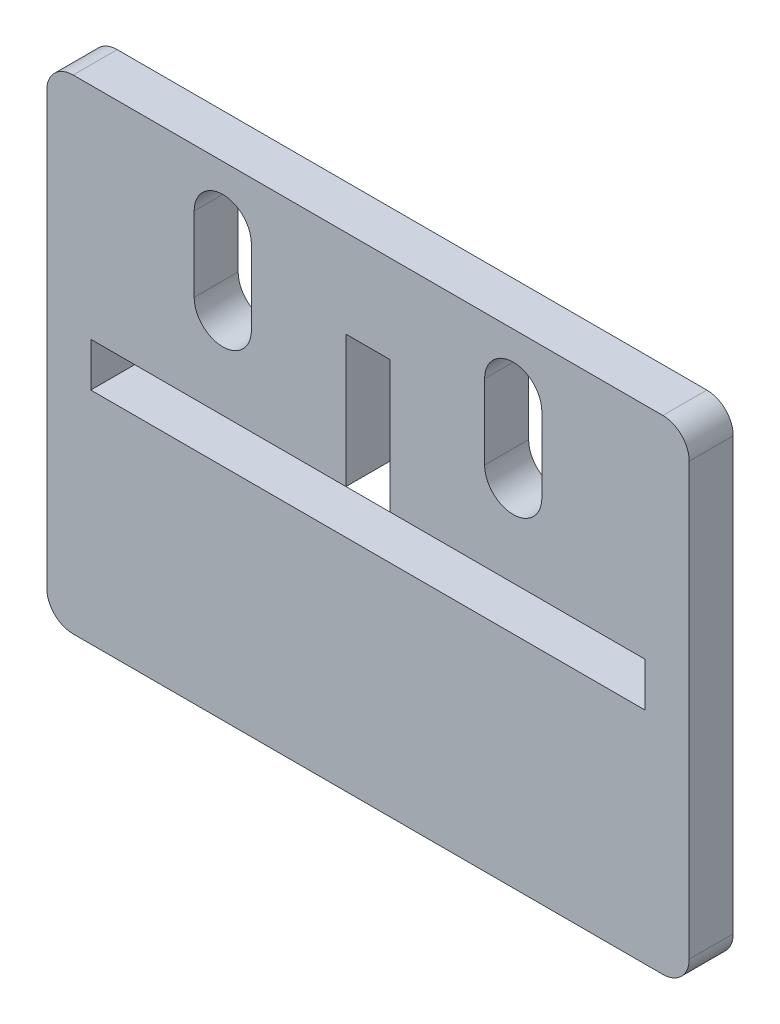
from build123d import *

# Parameters (mm, degrees)
EXTRUDE_1_DEPTH = 5


with BuildPart() as part:
    # 草图1 → 凸台-拉伸1 (new body)
    with BuildSketch(Plane.XY):
        with BuildLine():
            Line((33.5, -27.5), (-33.5, -27.5))
            ThreePointArc((-33.5, -27.5), (-35.621320344, -26.621320344), (-36.5, -24.5))
            Line((-36.5, -24.5), (-36.5, 24.5))
            ThreePointArc((-36.5, 24.5), (-35.621320344, 26.621320344), (-33.5, 27.5))
            Line((-33.5, 27.5), (33.5, 27.5))
            ThreePointArc((33.5, 27.5), (35.621320344, 26.621320344), (36.5, 24.5))
            Line((36.5, 24.5), (36.5, -24.5))
            ThreePointArc((36.5, -24.5), (35.621320344, -26.621320344), (33.5, -27.5))
        make_face()
        Polygon((-31.5, 2.5), (-31.5, -2.5), (31.5, -2.5), (31.5, 2.5), (2.5, 2.5), (2.5, 17.5), (-2.5, 17.5), (-2.5, 2.5), align=None, mode=Mode.SUBTRACT)
        with BuildLine():
            Line((13.25, 21), (13.25, 12.5))
            ThreePointArc((13.25, 12.5), (16.5, 9.25), (19.75, 12.5))
            Line((19.75, 12.5), (19.75, 21))
            ThreePointArc((19.75, 21), (16.5, 24.25), (13.25, 21))
        make_face(mode=Mode.SUBTRACT)
        with BuildLine():
            Line((-13.25, 21), (-13.25, 12.5))
            ThreePointArc((-13.25, 12.5), (-16.5, 9.25), (-19.75, 12.5))
            Line((-19.75, 12.5), (-19.75, 21))
            ThreePointArc((-19.75, 21), (-16.5, 24.25), (-13.25, 21))
        make_face(mode=Mode.SUBTRACT)
    extrude(amount=EXTRUDE_1_DEPTH)


solid = part.part
